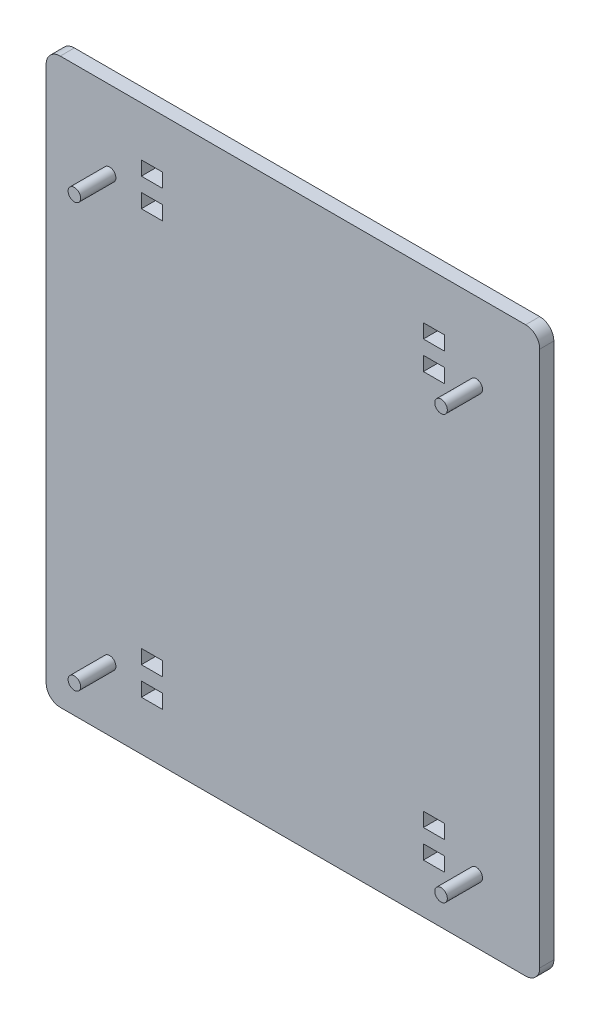
from build123d import *

# Parameters (mm, degrees)
SKETCH1_W           = 88.9
SKETCH1_H           = 101.6
BOSS_EXTRUDE1_DEPTH = 2.54
SKETCH2_R           = 1.1303
BOSS_EXTRUDE2_DEPTH = 6.35
SKETCH3_W           = 3.81
SKETCH3_H           = 2.54
CUT_EXTRUDE1_DEPTH  = 2.54
FILLET1_R           = 2.54


with BuildPart() as part:
    # Sketch1 → Boss-Extrude1 (new body)
    with BuildSketch(Plane.XY):
        with Locations((44.45, 50.8)):
            Rectangle(SKETCH1_W, SKETCH1_H)
    extrude(amount=BOSS_EXTRUDE1_DEPTH)

    # Sketch2 → Boss-Extrude2 (add)
    with BuildSketch(Plane.XY.offset(2.54)):
        with Locations((11.43, 87.6046)):
            Circle(SKETCH2_R)
        with Locations((77.47, 87.6046)):
            Circle(SKETCH2_R)
        with Locations((77.47, 11.4046)):
            Circle(SKETCH2_R)
        with Locations((11.43, 11.4046)):
            Circle(SKETCH2_R)
    extrude(amount=BOSS_EXTRUDE2_DEPTH)

    # Sketch3 → Cut-Extrude1 (cut)
    with BuildSketch(Plane.XY.offset(2.54)):
        with Locations((19.05, 15.24)):
            Rectangle(SKETCH3_W, SKETCH3_H)
        with Locations((69.85, 10.16)):
            Rectangle(SKETCH3_W, SKETCH3_H)
        with Locations((69.85, 15.24)):
            Rectangle(SKETCH3_W, SKETCH3_H)
        with Locations((19.05, 10.16)):
            Rectangle(SKETCH3_W, SKETCH3_H)
        with Locations((19.05, 86.36)):
            Rectangle(SKETCH3_W, SKETCH3_H)
        with Locations((19.05, 91.44)):
            Rectangle(SKETCH3_W, SKETCH3_H)
        with Locations((69.85, 86.36)):
            Rectangle(SKETCH3_W, SKETCH3_H)
        with Locations((69.85, 91.44)):
            Rectangle(SKETCH3_W, SKETCH3_H)
    extrude(amount=-CUT_EXTRUDE1_DEPTH, mode=Mode.SUBTRACT)

    # Fillet1
    fillet1_edges = [part.edges().sort_by_distance(p)[0] for p in [
        (0, 101.6, 1.27),
        (88.9, 101.6, 1.27),
        (88.9, 0, 1.27),
        (0, 0, 1.27),
    ]]
    fillet(fillet1_edges, radius=FILLET1_R)


solid = part.part
